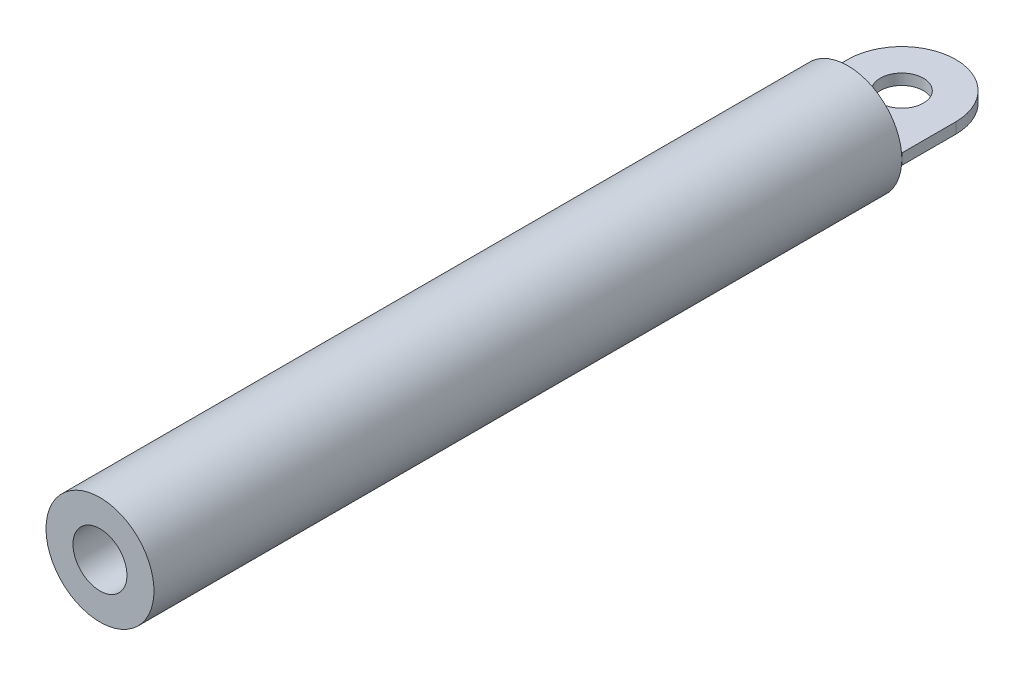
from build123d import *

# Parameters (mm, degrees)
BOSS_EXTRUDE1_DEPTH      = 0.3175
BOSS_EXTRUDE1_DEPTH_BACK = 0.3175
SKETCH1_10_R             = 1.27


with BuildPart() as part:
    # Sketch1 → Revolve6 (revolve)
    with BuildSketch(Plane(origin=(0, 0, 0), x_dir=(1, 0, 0), z_dir=(0, 1, 0))):
        Polygon((-3.175, -47.169090574), (-1.5875, -47.169090574), (-1.5875, -28.575), (-1.5875, -3.175), (-3.175, -3.175), align=None)
    revolve(axis=Axis((0, 0, 0), (0, 0, 1)))

    # Sketch1_10 → Boss-Extrude1 (add, two sides: drawn at the far end of the back side and taken through both)
    with BuildSketch(Plane(origin=(0, 0, 0), x_dir=(1, 0, 0), z_dir=(0, 1, 0)).offset(-BOSS_EXTRUDE1_DEPTH_BACK)):
        with BuildLine():
            Line((3.175, -3.175), (3.175, 0))
            ThreePointArc((3.175, 0), (0, 3.175), (-3.175, 0))
            Line((-3.175, 0), (-3.175, -3.175))
            Line((-3.175, -3.175), (3.175, -3.175))
        make_face()
        Circle(SKETCH1_10_R, mode=Mode.SUBTRACT)
    extrude(amount=BOSS_EXTRUDE1_DEPTH + BOSS_EXTRUDE1_DEPTH_BACK)


solid = part.part
